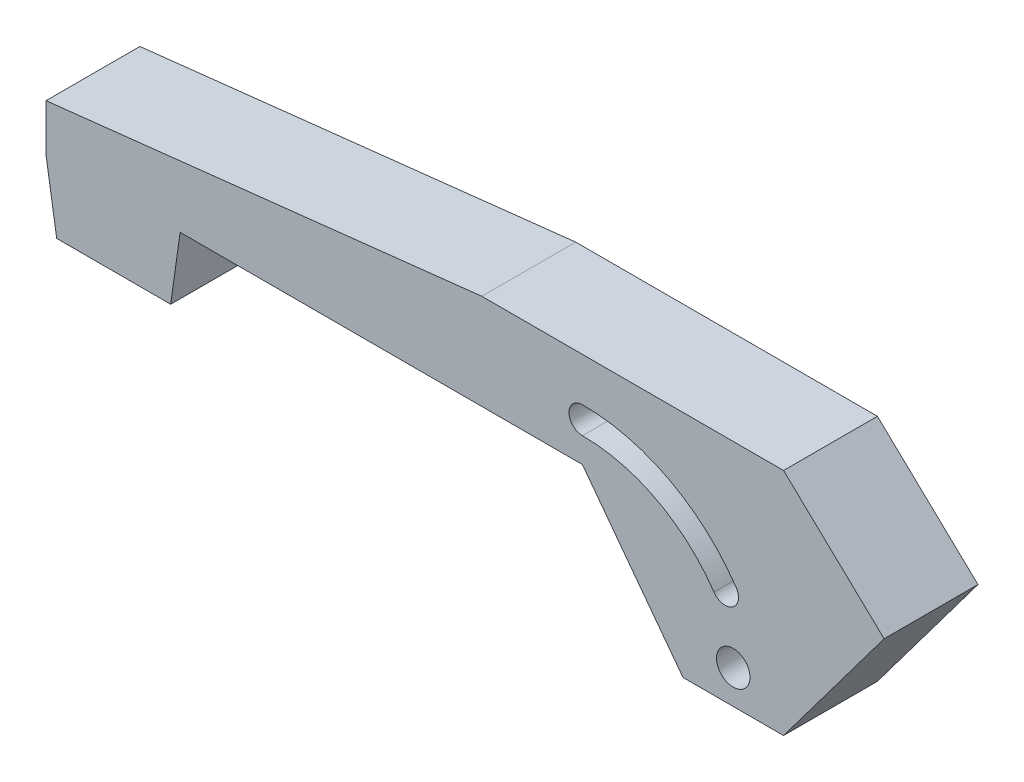
from build123d import *

# Parameters (mm, degrees)
BOSS_EXTRUDE1_DEPTH = 7
CUT_EXTRUDE1_DEPTH  = 8
CUT_EXTRUDE2_DEPTH  = 7
SKETCH5_R           = 1.25
CUT_EXTRUDE3_DEPTH  = 8
CUT_EXTRUDE4_DEPTH  = 8


with BuildPart() as part:
    # Sketch1 → Boss-Extrude1 (new body)
    with BuildSketch(Plane.XY):
        Polygon((0, 0), (10, 0), (10, 5), (40, 5), (47.5, -5), (55, -5), (62.5, 5), (55, 12.11693675), (47.5, 12.11693675), (32.5, 12.11693675), (0, 8.5), (0, 5), align=None)
    extrude(amount=BOSS_EXTRUDE1_DEPTH)

    # Sketch3 → Cut-Extrude1 (cut, through all)
    with BuildSketch(Plane.XY.offset(7)):
        Polygon((10, 5), (9.3, 0), (10, 0), align=None)
    extrude(amount=-CUT_EXTRUDE1_DEPTH, mode=Mode.SUBTRACT)

    # Sketch4 → Cut-Extrude2 (cut)
    with BuildSketch(Plane.XY.offset(7)):
        with BuildLine():
            ThreePointArc((51.468681491, 2.792101448), (46.488736675, 7.253317775), (40, 8.865334476))
            ThreePointArc((40, 8.865334476), (39, 7.865334476), (40, 6.865334476))
            ThreePointArc((40, 6.865334476), (45.552771274, 5.485842523), (49.814385807, 1.668132681))
            ThreePointArc((49.814385807, 1.668132681), (51.203518033, 1.402969222), (51.468681491, 2.792101448))
        make_face()
    extrude(amount=-CUT_EXTRUDE2_DEPTH, mode=Mode.SUBTRACT)

    # Sketch5 → Cut-Extrude3 (cut, through all)
    with BuildSketch(Plane.XY.offset(7)):
        with Locations((51.25, -2.5)):
            Circle(SKETCH5_R)
    extrude(amount=-CUT_EXTRUDE3_DEPTH, mode=Mode.SUBTRACT)

    # Sketch6 → Cut-Extrude4 (cut, through all)
    with BuildSketch(Plane.XY.offset(7)):
        Polygon((0, 0), (0.8, 0), (0, 5), align=None)
    extrude(amount=-CUT_EXTRUDE4_DEPTH, mode=Mode.SUBTRACT)


solid = part.part
